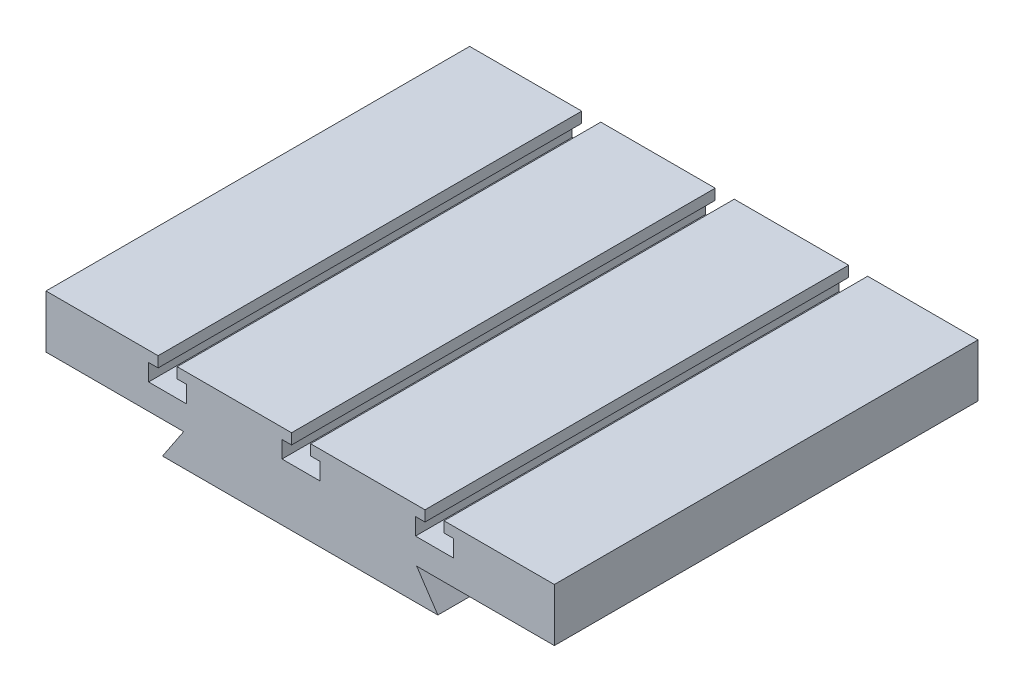
from build123d import *

# Parameters (mm, degrees)
EXTRUDE_1_DEPTH     = 200
CUT_EXTRUDE_1_DEPTH = 201


with BuildPart() as part:
    # Эскиз1 → Бобышка-Вытянуть1 (new body)
    with BuildSketch(Plane.XY):
        Polygon((0, 0), (65, 0), (55, 15), (120, 15), (120, 40), (0, 40), (-120, 40), (-120, 15), (-55, 15), (-65, 0), align=None)
    extrude(amount=EXTRUDE_1_DEPTH)

    # Эскиз2 → Вырез-Вытянуть1 (cut, through all)
    with BuildSketch(Plane.XY.offset(200)):
        Polygon((-8.573821021, 27), (9.426178979, 27), (9.426178979, 35), (4.926178979, 35), (4.926178979, 40), (-4.073821021, 40), (-4.073821021, 35), (-8.573821021, 35), align=None)
        Polygon((54.426178979, 27), (72.426178979, 27), (72.426178979, 35), (67.926178979, 35), (67.926178979, 40), (58.926178979, 40), (58.926178979, 35), (54.426178979, 35), align=None)
        Polygon((-71.573821021, 27), (-53.573821021, 27), (-53.573821021, 35), (-58.073821021, 35), (-58.073821021, 40), (-67.073821021, 40), (-67.073821021, 35), (-71.573821021, 35), align=None)
    extrude(amount=-CUT_EXTRUDE_1_DEPTH, mode=Mode.SUBTRACT)


solid = part.part
